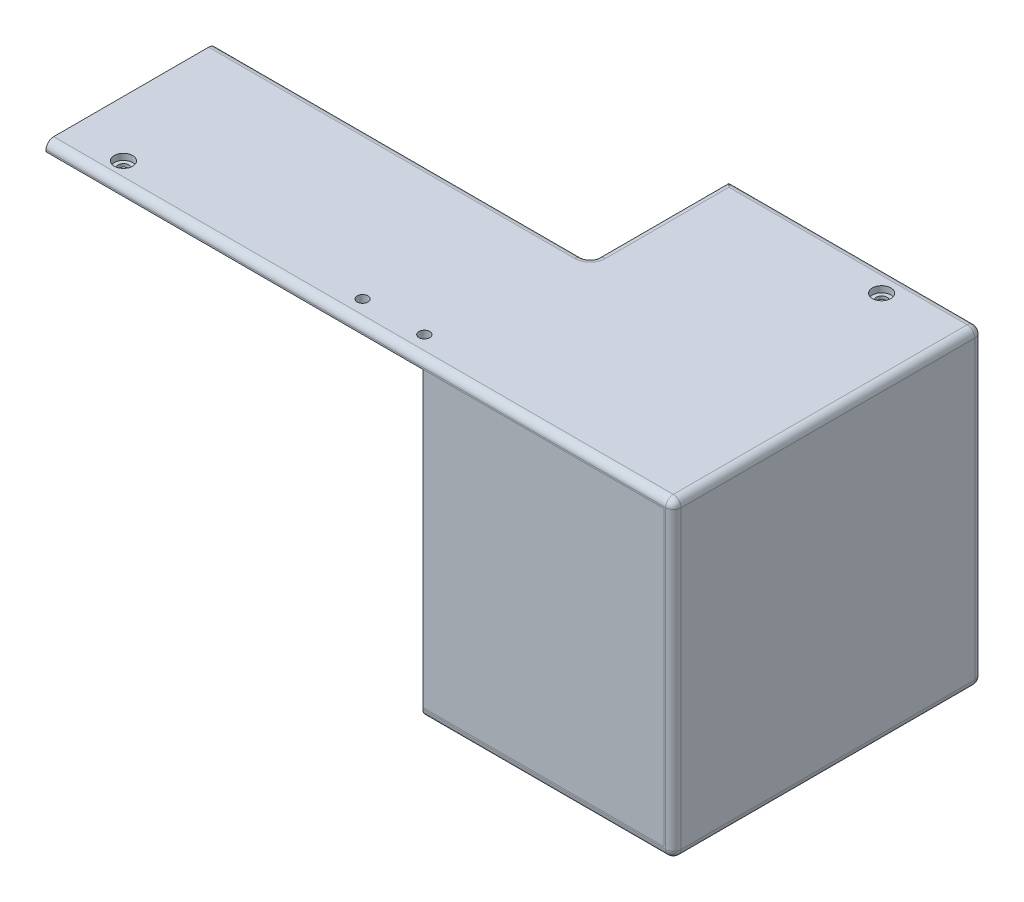
from build123d import *

# Parameters (mm, degrees)
MAIN_BODY_DEPTH              = 100.2
SKETCH4_R                    = 1.75
BACK_SCREW_HOLES_DEPTH       = 3
SKETCH5_R                    = 3
BACK_SCREW_HEADS_DEPTH       = 2
SKETCH7_W                    = 213.220218809
SKETCH7_H                    = 45
PAPER_THROUGH_HOLE_DEPTH     = 10
SKETCH8_W                    = 78.2
SKETCH8_H                    = 94.9
TOP_DEPTH                    = 3
SKETCH9_R                    = 1.75
FRONT_RIGHT_SCREW_HOLE_DEPTH = 3
SKETCH11_R                   = 3
FRONT_RIGHT_SCREW_HEAD_DEPTH = 2
SKETCH19_R                   = 1.75
LATCH_SCREW_HOLE_DEPTH       = 3
SKETCH20_R                   = 1.75
CUT_EXTRUDE1_DEPTH           = 10
FILLET2_R                    = 2.5


with BuildPart() as part:
    # Sketch1 → Main_Body (new body)
    with BuildSketch(Plane.XY):
        Polygon((0, 0), (203.3, 0), (203.3, -100.9), (122.1, -100.9), (122.1, -97.9), (200.3, -97.9), (200.3, -3), (0, -3), align=None)
    extrude(amount=MAIN_BODY_DEPTH)

    # Sketch4 → Back_Screw_Holes (cut)
    with BuildSketch(Plane(origin=(0, 0, 0), x_dir=(1, 0, 0), z_dir=(0, 1, 0))):
        with Locations((178.1, -7.5)):
            Circle(SKETCH4_R)
        with Locations((18.1, -7.5)):
            Circle(SKETCH4_R)
        with Locations((18.1, -93.2)):
            Circle(SKETCH4_R)
    extrude(amount=-BACK_SCREW_HOLES_DEPTH, mode=Mode.SUBTRACT)

    # Sketch5 → Back_Screw_Heads (cut)
    with BuildSketch(Plane(origin=(0, 0, 0), x_dir=(1, 0, 0), z_dir=(0, 1, 0))):
        with Locations((18.1, -7.5)):
            Circle(SKETCH5_R)
        with Locations((178.1, -7.5)):
            Circle(SKETCH5_R)
        with Locations((18.1, -93.2)):
            Circle(SKETCH5_R)
    extrude(amount=-BACK_SCREW_HEADS_DEPTH, mode=Mode.SUBTRACT)

    # Sketch7 → Paper_Through_Hole (cut)
    with BuildSketch(Plane.XZ.offset(3)):
        with Locations((14.489890596, 22.5)):
            Rectangle(SKETCH7_W, SKETCH7_H)
    extrude(amount=-PAPER_THROUGH_HOLE_DEPTH, mode=Mode.SUBTRACT)

    # Sketch9 → Front_Right_Screw_Hole (cut)
    with BuildSketch(Plane.XZ.offset(100.9)):
        with Locations((178.1, 7.5)):
            Circle(SKETCH9_R)
    extrude(amount=-FRONT_RIGHT_SCREW_HOLE_DEPTH, mode=Mode.SUBTRACT)

    # Sketch11 → Front_Right_Screw_Head (cut)
    with BuildSketch(Plane.XZ.offset(100.9)):
        with Locations((178.1, 7.5)):
            Circle(SKETCH11_R)
    extrude(amount=-FRONT_RIGHT_SCREW_HEAD_DEPTH, mode=Mode.SUBTRACT)

    # Sketch19 → Latch_Screw_Hole (cut)
    with BuildSketch(Plane.XZ.offset(100.9)):
        with Locations((132.1, 43)):
            Circle(SKETCH19_R)
    extrude(amount=-LATCH_SCREW_HOLE_DEPTH, mode=Mode.SUBTRACT)

    # Sketch20 → Cut-Extrude1 (cut)
    with BuildSketch(Plane(origin=(0, 0, 0), x_dir=(1, 0, 0), z_dir=(0, 1, 0))):
        with Locations((95.6, -93.2)):
            Circle(SKETCH20_R)
        with Locations((115.6, -93.2)):
            Circle(SKETCH20_R)
    extrude(amount=-CUT_EXTRUDE1_DEPTH, mode=Mode.SUBTRACT)

    # Fillet2
    fillet2_edges = [part.edges().sort_by_distance(p)[0] for p in [
        (203.3, 0, 50.1),
        (203.3, -100.9, 50.1),
        (162.7, -100.9, 100.2),
        (203.3, -50.45, 100.2),
        (101.65, 0, 100.2),
        (60.55, 0, 45),
        (121.1, 0, 22.5),
        (121.1, -1.5, 45),
        (162.2, 0, 0),
        (203.3, -50.45, 0),
        (162.7, -100.9, 0),
    ]]
    fillet(fillet2_edges, radius=FILLET2_R)


with BuildPart() as body_2:
    # Sketch8 → Top (new body)
    with BuildSketch(Plane.XY.offset(100.2)):
        with Locations((161.2, -50.45)):
            Rectangle(SKETCH8_W, SKETCH8_H)
    extrude(amount=-TOP_DEPTH)


solid = Compound([part.part, body_2.part])
